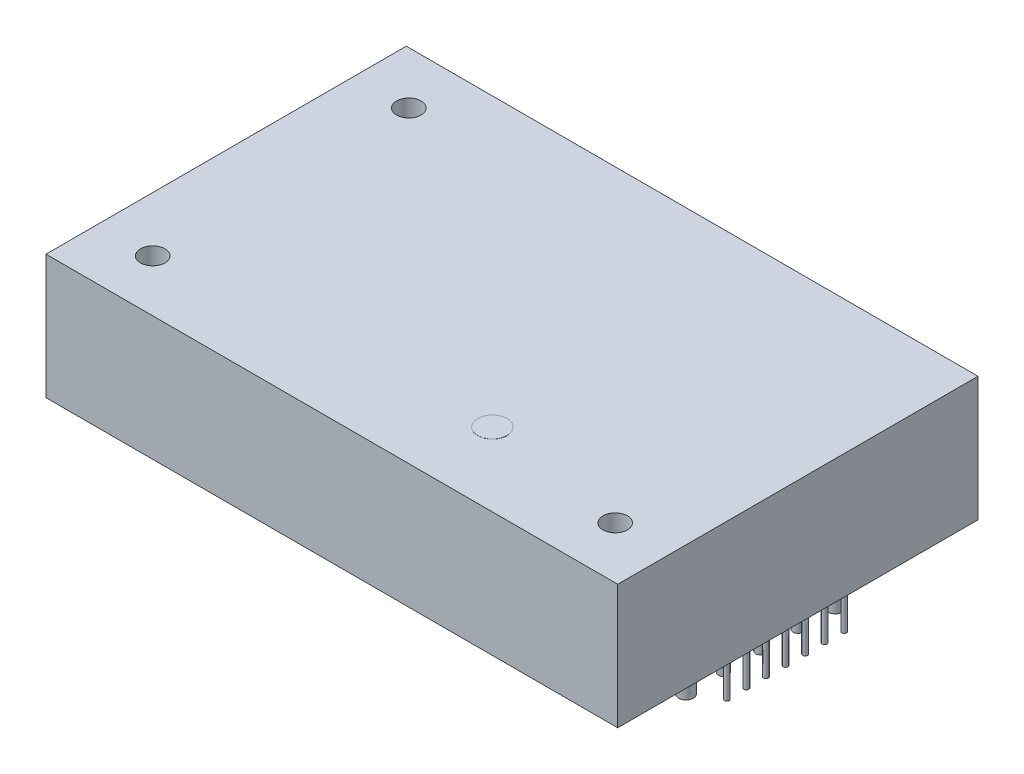
from build123d import *

# Parameters (mm, degrees)
SKETCH1_W                 = 58.4
SKETCH1_H                 = 36.8
BOSS_EXTRUDE1_DEPTH       = 12.7
SKETCH2_R                 = 0.5
SKETCH2_R_2               = 0.75
SKETCH2_R_3               = 0.25
BOSS_EXTRUDE2_DEPTH       = 4.3
M3X0_5_TAPPED_HOLE1_D     = 2.5
M3X0_5_TAPPED_HOLE1_DEPTH = 4.5
M3X0_5_TAPPED_HOLE1_TIP   = 0.751075774
SKETCH6_R                 = 1.5
BOSS_EXTRUDE3_DEPTH       = 0.01


with BuildPart() as part:
    # Sketch1 → Boss-Extrude1 (new body)
    with BuildSketch(Plane(origin=(0, 0, 0), x_dir=(1, 0, 0), z_dir=(0, 1, 0))):
        Rectangle(SKETCH1_W, SKETCH1_H)
    extrude(amount=BOSS_EXTRUDE1_DEPTH)

    # Sketch2 → Boss-Extrude2 (add)
    with BuildSketch(Plane.XZ):
        with Locations((-25.4, 0)):
            Circle(SKETCH2_R)
        with Locations((-25.4, 3.81)):
            Circle(SKETCH2_R)
        with Locations((-25.4, 7.62)):
            Circle(SKETCH2_R)
        with Locations((-25.4, -7.62)):
            Circle(SKETCH2_R)
        with Locations((25.4, 7.62)):
            Circle(SKETCH2_R_2)
        with Locations((25.4, 3.81)):
            Circle(SKETCH2_R)
        with Locations((25.4, 0)):
            Circle(SKETCH2_R)
        with Locations((25.4, -3.81)):
            Circle(SKETCH2_R)
        with Locations((25.4, -7.62)):
            Circle(SKETCH2_R_2)
        with Locations((27.94, 0)):
            Circle(SKETCH2_R_3)
        with Locations((27.94, -2)):
            Circle(SKETCH2_R_3)
        with Locations((27.94, -4)):
            Circle(SKETCH2_R_3)
        with Locations((27.94, -6)):
            Circle(SKETCH2_R_3)
        with Locations((27.94, 2)):
            Circle(SKETCH2_R_3)
        with Locations((27.94, 4)):
            Circle(SKETCH2_R_3)
        with Locations((27.94, 6)):
            Circle(SKETCH2_R_3)
    extrude(amount=BOSS_EXTRUDE2_DEPTH)

    # M3x0.5 Tapped Hole1
    with Locations(Plane(origin=(-23.6, 12.7, -13.06), x_dir=(0, 0, 1), z_dir=(0, 1, 0))):
        with Locations((0, 0), (26.16, 0), (26.16, 47.24)):
            Hole(M3X0_5_TAPPED_HOLE1_D / 2, depth=M3X0_5_TAPPED_HOLE1_DEPTH)
            with Locations((0, 0, -(M3X0_5_TAPPED_HOLE1_DEPTH + M3X0_5_TAPPED_HOLE1_TIP / 2))):  # 118° drill point
                Cone(0, M3X0_5_TAPPED_HOLE1_D / 2, M3X0_5_TAPPED_HOLE1_TIP, mode=Mode.SUBTRACT)

    # Sketch6 → Boss-Extrude3 (add)
    with BuildSketch(Plane(origin=(0, 12.7, 0), x_dir=(1, 0, 0), z_dir=(0, 1, 0))):
        with Locations((8.9, -10.9)):
            Circle(SKETCH6_R)
    extrude(amount=BOSS_EXTRUDE3_DEPTH)


solid = part.part
